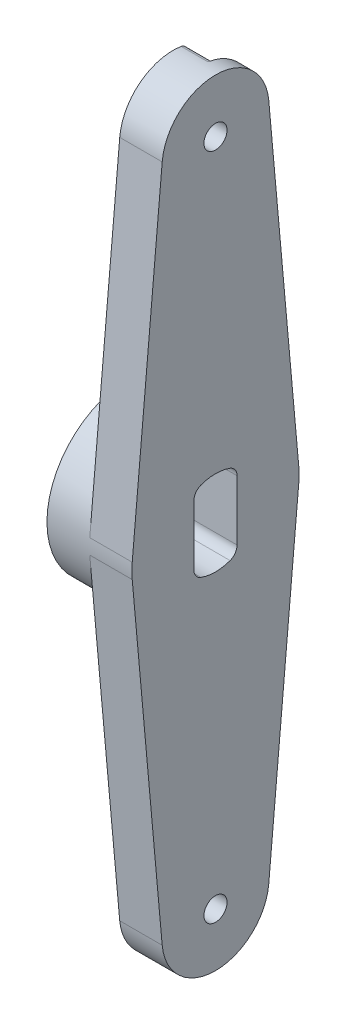
from build123d import *
from build123d.topology import SkipClean

# Parameters (mm, degrees)
BOSS_EXTRUDE1_DEPTH = 6.35
SKETCH3_R           = 3.5
CUT_EXTRUDE1_DEPTH  = 4
FILLET1_R           = 1
SKETCH4_R           = 12.5
BOSS_EXTRUDE2_DEPTH = 6.35
CUT_EXTRUDE2_DEPTH  = 13.7
FILLET2_R           = 1
FILLET3_R           = 1.5875
SKETCH9_R           = 3.5
CUT_EXTRUDE3_DEPTH  = 2.2


with BuildPart() as part:
    # Sketch2 → Boss-Extrude1 (new body)
    with BuildSketch(Plane(origin=(0, 0, 0), x_dir=(0, 0, -1), z_dir=(1, 0, 0))):
        with BuildLine():
            Line((-12.449272067, -1.125), (-7.967534123, -50.72))
            ThreePointArc((-7.967534123, -50.72), (0, -58), (7.967534123, -50.72))
            Line((7.967534123, -50.72), (12.449272067, -1.125))
            ThreePointArc((12.449272067, -1.125), (12.5, 0), (12.449272067, 1.125))
            Line((12.449272067, 1.125), (7.967534123, 50.72))
            ThreePointArc((7.967534123, 50.72), (0, 58), (-7.967534123, 50.72))
            Line((-7.967534123, 50.72), (-12.449272067, 1.125))
            ThreePointArc((-12.449272067, 1.125), (-12.5, 0), (-12.449272067, -1.125))
        make_face()
    extrude(amount=-BOSS_EXTRUDE1_DEPTH)

    # Sketch3 → Cut-Extrude1 (cut)
    with BuildSketch(Plane.ZY.offset(6.35)):
        with BuildLine():
            Line((-4.118569102, 56.858380899), (1.62233922, 54.993046711))
            ThreePointArc((1.62233922, 54.993046711), (5.25, 50), (1.62233922, 45.006953289))
            Line((1.62233922, 45.006953289), (-8.789515625, 41.623936576))
            Line((-8.789515625, 41.623936576), (-7.967534123, 50.72))
            ThreePointArc((-7.967534123, 50.72), (-6.777787456, 54.249893786), (-4.118569102, 56.858380899))
        make_face()
        with Locations((0, 50)):
            Circle(SKETCH3_R, mode=Mode.SUBTRACT)
    cut_extrude1 = extrude(amount=-CUT_EXTRUDE1_DEPTH, mode=Mode.SUBTRACT)

    # Fillet1
    fillet1_edges = [part.edges().sort_by_distance(p)[0] for p in [
        (-4.35, 56.858380899, -4.118569102),
        (-4.35, 41.623936576, -8.789515625),
    ]]
    fillet(fillet1_edges, radius=FILLET1_R)

    # Mirror1: Cut-Extrude1 across plane
    add(cut_extrude1.mirror(Plane.ZX), mode=Mode.SUBTRACT)

    # Sketch4 → Boss-Extrude2 (add)
    with SkipClean():  # keep this step's faces unmerged: merging them makes the solid invalid here
        with BuildSketch(Plane.ZY.offset(6.35)):
            with Locations(Location((0, 0, 0), (0, 0, 174.836392909))):  # turned: the seam where the file's is
                Circle(SKETCH4_R)
        extrude(amount=BOSS_EXTRUDE2_DEPTH)

    # Sketch5 → Cut-Extrude2 (cut, through all)
    with SkipClean():  # keep this step's faces unmerged: merging them makes the solid invalid here
        with BuildSketch(Plane.ZY.offset(12.7)):
            with BuildLine():
                Line((-3.2258, 5.484356448), (-3.2258, -5.484356448))
                ThreePointArc((-3.2258, -5.484356448), (0, -6.3627), (3.2258, -5.484356448))
                Line((3.2258, -5.484356448), (3.2258, 5.484356448))
                ThreePointArc((3.2258, 5.484356448), (0, 6.3627), (-3.2258, 5.484356448))
            make_face()
        extrude(amount=-CUT_EXTRUDE2_DEPTH, mode=Mode.SUBTRACT)

    # Fillet2
    fillet2_edges = [part.edges().sort_by_distance(p)[0] for p in [
        (-4.35, -56.858380899, -4.118569102),
        (-4.35, -41.623936576, -8.789515625),
    ]]
    fillet(fillet2_edges, radius=FILLET2_R)

    # Fillet3
    fillet3_edges = [part.edges().sort_by_distance(p)[0] for p in [
        (-6.35, 5.484356448, -3.2258),
        (-6.35, 5.484356448, 3.2258),
        (-6.35, -5.484356448, 3.2258),
        (-6.35, -5.484356448, -3.2258),
    ]]
    fillet(fillet3_edges, radius=FILLET3_R)

    # Sketch9 → Cut-Extrude3 (cut)
    with SkipClean():  # keep this step's faces unmerged: merging them makes the solid invalid here
        with BuildSketch(Plane.ZY.offset(6.35)):
            with Locations((0, 50)):
                Circle(SKETCH9_R)
        cut_extrude3 = extrude(amount=-CUT_EXTRUDE3_DEPTH, mode=Mode.SUBTRACT)

    # Sketch7 → #8-32 Tapped Hole1 (revolve, cut)
    with SkipClean():  # keep this step's faces unmerged: merging them makes the solid invalid here
        with BuildSketch(Plane(origin=(-6.35, 50, 0), x_dir=(0, 0, 1), z_dir=(0, 1, 0))):
            Polygon((0, 0), (0, 13.327806461), (1.7272, 12.29), (1.7272, 0), align=None)
        f_8_32_tapped_hole1 = revolve(axis=Axis((-12.7, 50, 0), (1, 0, 0)), mode=Mode.SUBTRACT)

    # Mirror2: Cut-Extrude3, #8-32 Tapped Hole1 across plane
    with SkipClean():  # keep this step's faces unmerged: merging them makes the solid invalid here
        add(cut_extrude3.mirror(Plane.ZX), mode=Mode.SUBTRACT)
        add(f_8_32_tapped_hole1.mirror(Plane.ZX), mode=Mode.SUBTRACT)


solid = part.part
